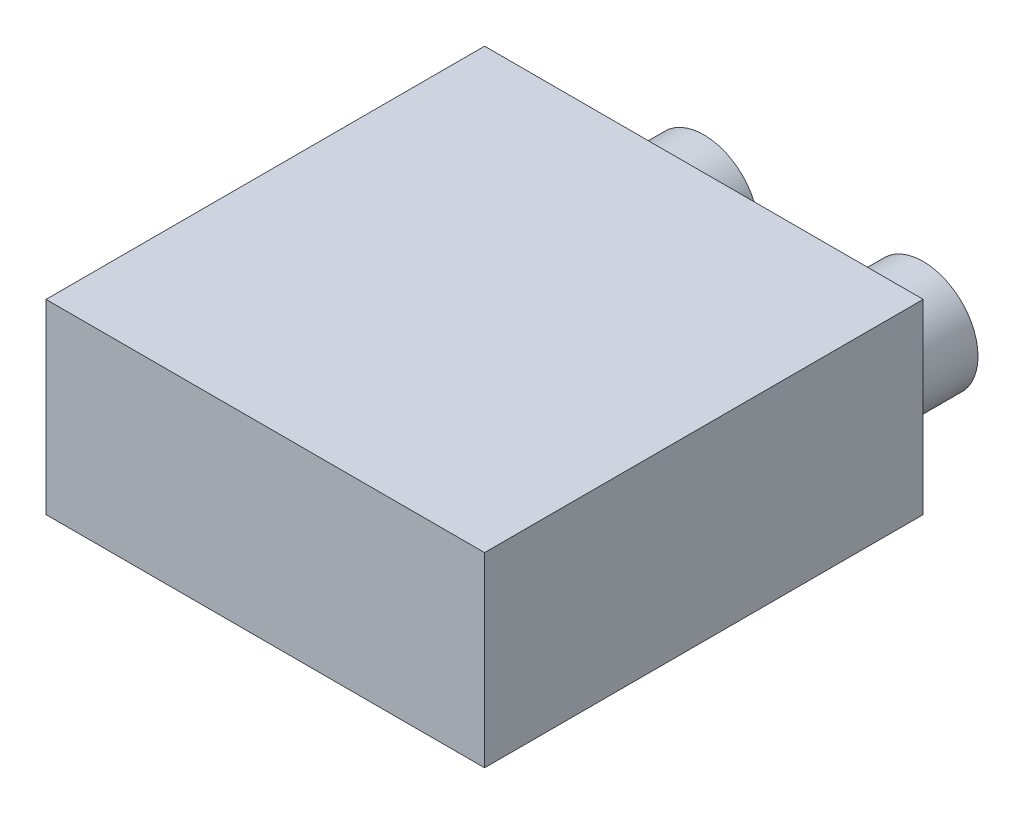
from build123d import *

# Parameters (mm, degrees)
SKETCH1_W           = 40
SKETCH1_H           = 40
BOSS_EXTRUDE1_DEPTH = 17
SKETCH2_R           = 5
BOSS_EXTRUDE2_DEPTH = 10


with BuildPart() as part:
    # Sketch1 → Boss-Extrude1 (new body)
    with BuildSketch(Plane(origin=(0, 0, 0), x_dir=(1, 0, 0), z_dir=(0, 1, 0))):
        Rectangle(SKETCH1_W, SKETCH1_H)
    extrude(amount=BOSS_EXTRUDE1_DEPTH)

    # Sketch2 → Boss-Extrude2 (add)
    with BuildSketch(Plane(origin=(0, 0, -20), x_dir=(-1, 0, 0), z_dir=(0, 0, -1))):
        with Locations((10, 5)):
            Circle(SKETCH2_R)
    boss_extrude2 = extrude(amount=BOSS_EXTRUDE2_DEPTH)

    # Mirror1: Boss-Extrude2 across plane
    add(boss_extrude2.mirror(Plane(origin=(0, 0, 0), x_dir=(0, 0, 1), z_dir=(1, 0, 0))))


solid = part.part
